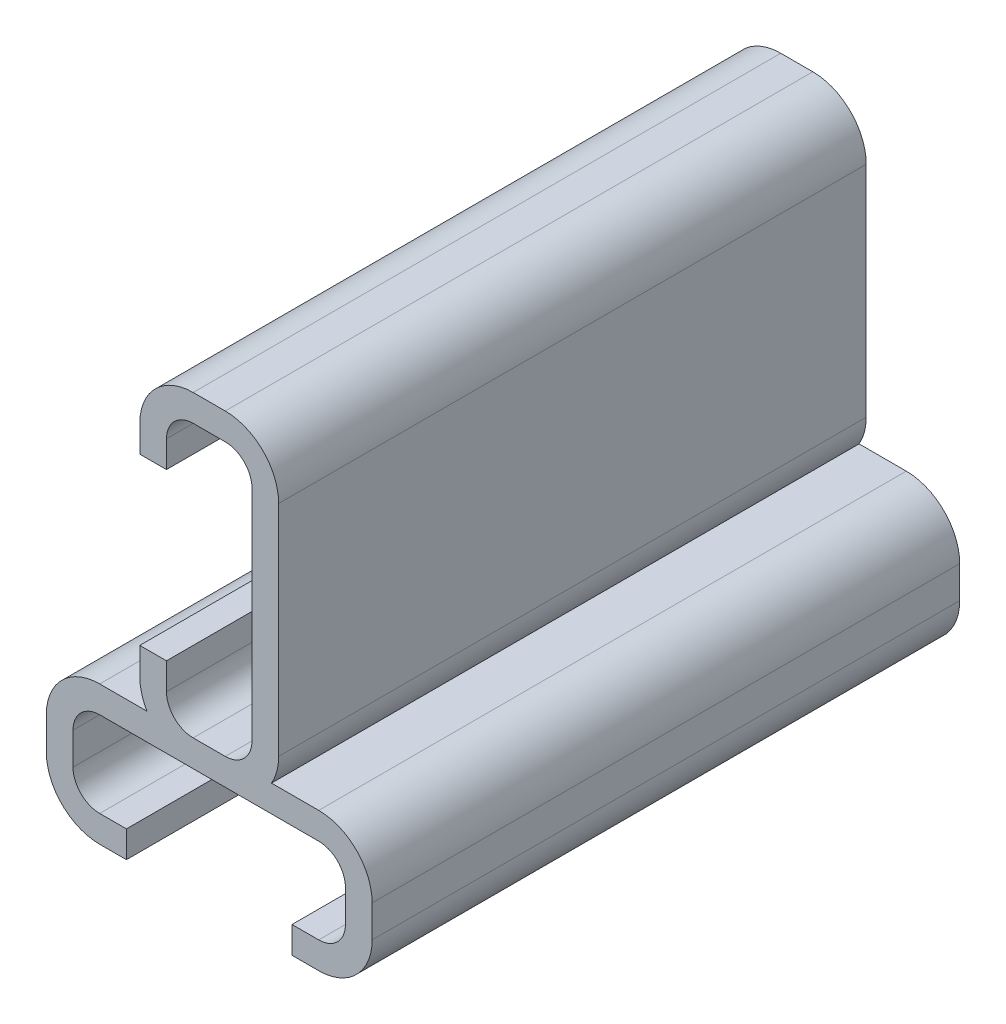
from build123d import *

# Parameters (mm, degrees)
BOSS_EXTRU_2_DEPTH      = 10
BOSS_EXTRU_4_DEPTH      = 1
ESQUISSE5_W             = 6.2
ESQUISSE5_H             = 10
ENL_V_MAT_EXTRU_1_DEPTH = 1
ESQUISSE6_W             = 10
ESQUISSE6_H             = 6.2
ENL_V_MAT_EXTRU_2_DEPTH = 1


with BuildPart() as part:
    # Esquisse1 → Boss.-Extru.2 (new body)
    with BuildSketch(Plane.XY):
        with BuildLine():
            Line((6.1, 0.6), (6.1, -0.6))
            ThreePointArc((6.1, -0.6), (5.514213562, -2.014213562), (4.1, -2.6))
            Line((4.1, -2.6), (-4.1, -2.6))
            ThreePointArc((-4.1, -2.6), (-5.514213562, -2.014213562), (-6.1, -0.6))
            Line((-6.1, -0.6), (-6.1, 0.6))
            ThreePointArc((-6.1, 0.6), (-5.514213562, 2.014213562), (-4.1, 2.6))
            Line((-4.1, 2.6), (-2.332050808, 2.6))
            ThreePointArc((-2.332050808, 2.6), (-2.531851653, 3.08236191), (-2.6, 3.6))
            Line((-2.6, 3.6), (-2.6, 11.8))
            ThreePointArc((-2.6, 11.8), (-2.014213562, 13.214213562), (-0.6, 13.8))
            Line((-0.6, 13.8), (0.6, 13.8))
            ThreePointArc((0.6, 13.8), (2.014213562, 13.214213562), (2.6, 11.8))
            Line((2.6, 11.8), (2.6, 3.6))
            ThreePointArc((2.6, 3.6), (2.531851653, 3.08236191), (2.332050808, 2.6))
            Line((2.332050808, 2.6), (4.1, 2.6))
            ThreePointArc((4.1, 2.6), (5.514213562, 2.014213562), (6.1, 0.6))
        make_face()
        with BuildLine():
            Line((5.1, 0.6), (5.1, -0.6))
            ThreePointArc((5.1, -0.6), (4.807106781, -1.307106781), (4.1, -1.6))
            Line((4.1, -1.6), (-4.1, -1.6))
            ThreePointArc((-4.1, -1.6), (-4.807106781, -1.307106781), (-5.1, -0.6))
            Line((-5.1, -0.6), (-5.1, 0.6))
            ThreePointArc((-5.1, 0.6), (-4.807106781, 1.307106781), (-4.1, 1.6))
            Line((-4.1, 1.6), (4.1, 1.6))
            ThreePointArc((4.1, 1.6), (4.807106781, 1.307106781), (5.1, 0.6))
        make_face(mode=Mode.SUBTRACT)
        with BuildLine():
            Line((-0.6, 2.6), (0.6, 2.6))
            ThreePointArc((0.6, 2.6), (1.307106781, 2.892893219), (1.6, 3.6))
            Line((1.6, 3.6), (1.6, 11.8))
            ThreePointArc((1.6, 11.8), (1.307106781, 12.507106781), (0.6, 12.8))
            Line((0.6, 12.8), (-0.6, 12.8))
            ThreePointArc((-0.6, 12.8), (-1.307106781, 12.507106781), (-1.6, 11.8))
            Line((-1.6, 11.8), (-1.6, 3.6))
            ThreePointArc((-1.6, 3.6), (-1.307106781, 2.892893219), (-0.6, 2.6))
        make_face(mode=Mode.SUBTRACT)
    boss_extru_2 = extrude(amount=BOSS_EXTRU_2_DEPTH)

    # Esquisse7 → Boss.-Extru.4 (add)
    with BuildSketch(Plane(origin=(0, 0, 0), x_dir=(-1, 0, 0), z_dir=(0, 0, -1))):
        with BuildLine():
            Line((-6.1, 0.6), (-6.1, -0.6))
            ThreePointArc((-6.1, -0.6), (-5.514213562, -2.014213562), (-4.1, -2.6))
            Line((-4.1, -2.6), (4.1, -2.6))
            ThreePointArc((4.1, -2.6), (5.514213562, -2.014213562), (6.1, -0.6))
            Line((6.1, -0.6), (6.1, 0.6))
            ThreePointArc((6.1, 0.6), (5.514213562, 2.014213562), (4.1, 2.6))
            Line((4.1, 2.6), (2.332050808, 2.6))
            ThreePointArc((2.332050808, 2.6), (2.531851653, 3.08236191), (2.6, 3.6))
            Line((2.6, 3.6), (2.6, 11.8))
            ThreePointArc((2.6, 11.8), (2.014213562, 13.214213562), (0.6, 13.8))
            Line((0.6, 13.8), (-0.6, 13.8))
            ThreePointArc((-0.6, 13.8), (-2.014213562, 13.214213562), (-2.6, 11.8))
            Line((-2.6, 11.8), (-2.6, 3.6))
            ThreePointArc((-2.6, 3.6), (-2.531851653, 3.08236191), (-2.332050808, 2.6))
            Line((-2.332050808, 2.6), (-4.1, 2.6))
            ThreePointArc((-4.1, 2.6), (-5.514213562, 2.014213562), (-6.1, 0.6))
        make_face()
    boss_extru_4 = extrude(amount=BOSS_EXTRU_4_DEPTH)

    # Symétrie1: Boss.-Extru.2, Boss.-Extru.4 across plane
    add(boss_extru_2.mirror(Plane(origin=(4.1, 0.6, -1), x_dir=(1, 0, 0), z_dir=(0, 0, -1))))
    add(boss_extru_4.mirror(Plane(origin=(4.1, 0.6, -1), x_dir=(1, 0, 0), z_dir=(0, 0, -1))))

    # Esquisse5 → Enlèv. mat.-Extru.1 (cut)
    with BuildSketch(Plane.XZ.offset(2.6)):
        with Locations((0, -7)):
            Rectangle(ESQUISSE5_W, ESQUISSE5_H)
        with Locations((0, 5)):
            Rectangle(ESQUISSE5_W, ESQUISSE5_H)
    extrude(amount=-ENL_V_MAT_EXTRU_1_DEPTH, mode=Mode.SUBTRACT)

    # Esquisse6 → Enlèv. mat.-Extru.2 (cut)
    with BuildSketch(Plane(origin=(-2.6, 0, 0), x_dir=(0, 0, -1), z_dir=(1, 0, 0))):
        with Locations((7, 7.7)):
            Rectangle(ESQUISSE6_W, ESQUISSE6_H)
        with Locations((-5, 7.7)):
            Rectangle(ESQUISSE6_W, ESQUISSE6_H)
    extrude(amount=ENL_V_MAT_EXTRU_2_DEPTH, mode=Mode.SUBTRACT)


solid = part.part
